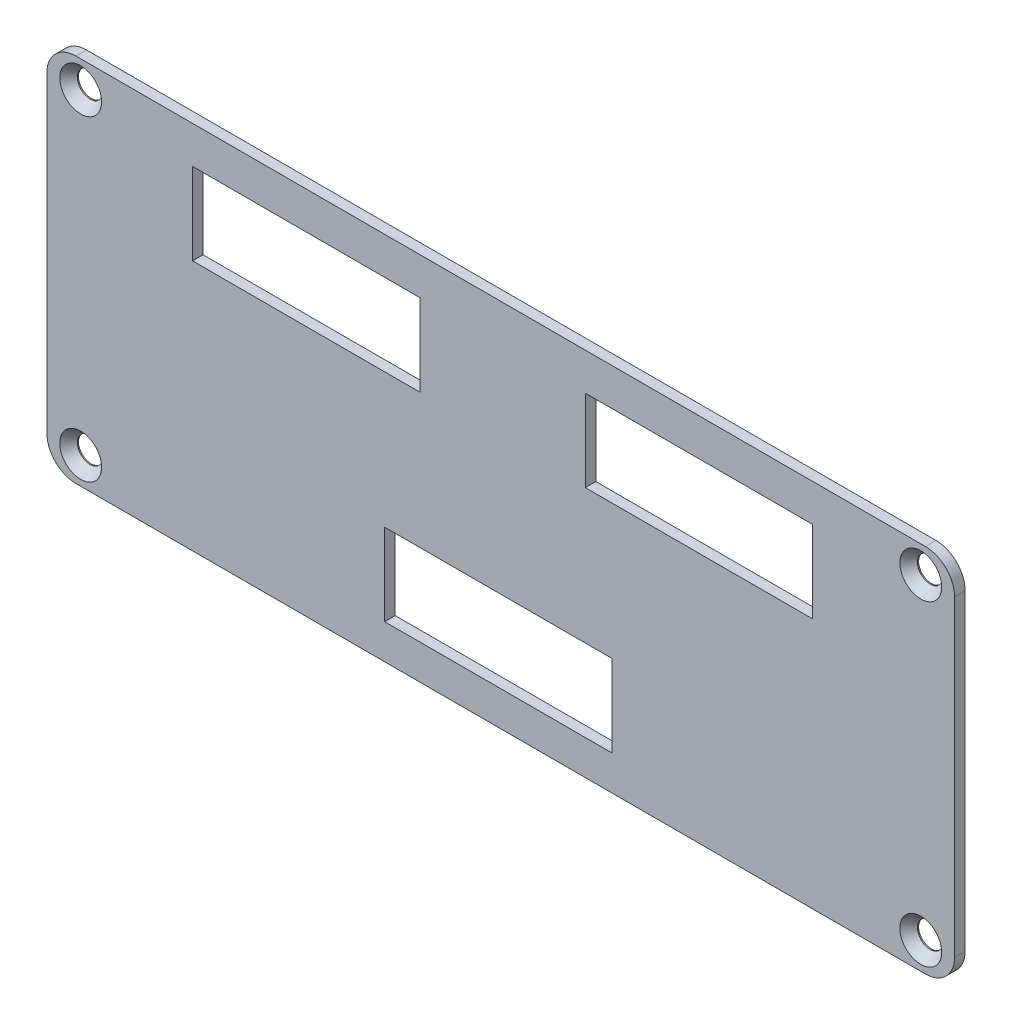
from build123d import *

# Parameters (mm, degrees)
SKETCH1_W                                      = 124.8
SKETCH1_H                                      = 50.9
BOSS_EXTRUDE1_DEPTH                            = 1.45
CSK_FOR_M3_5_FLAT_HEAD_MACHINE_SCREW1_AT_COUNT = 2
CSK_FOR_M3_5_FLAT_HEAD_MACHINE_SCREW1_AT_PITCH = 115.5
CSK_FOR_M3_5_FLAT_HEAD_MACHINE_SCREW_2_COUNT   = 2
CSK_FOR_M3_5_FLAT_HEAD_MACHINE_SCREW_2_PITCH   = 123.420014584
CSK_FOR_M3_5_FLAT_HEAD_MACHINE_SCREW_3_COUNT   = 2
CSK_FOR_M3_5_FLAT_HEAD_MACHINE_SCREW_3_PITCH   = 43.5
FILLET2_R                                      = 4
SKETCH4_W                                      = 31.25
SKETCH4_H                                      = 11.25
CUT_EXTRUDE1_DEPTH                             = 1.45


with BuildPart() as part:
    # Sketch1 → Boss-Extrude1 (new body)
    with BuildSketch(Plane.XY):
        with Locations((62.4, -25.45)):
            Rectangle(SKETCH1_W, SKETCH1_H)
    extrude(amount=BOSS_EXTRUDE1_DEPTH)

    # Sketch2 → CSK for M3.5 Flat Head Machine Screw1 (revolve, cut)
    with BuildSketch(Plane(origin=(4.65, -3.7, 1.45), x_dir=(0, -1, 0), z_dir=(1, 0, 0))):
        Polygon((0, 0), (0, 1.45), (1.75, 1.45), (1.75, 1.294164458), (2.875, 0), align=None)
    csk_for_m3_5_flat_head_machine_screw1 = revolve(axis=Axis((4.65, -3.7, 7.8), (0, 0, -1)), mode=Mode.SUBTRACT)

    # CSK for M3.5 Flat Head Machine Screw1 at: CSK for M3.5 Flat Head Machine Screw1 ×2
    with Locations(*[(i * CSK_FOR_M3_5_FLAT_HEAD_MACHINE_SCREW1_AT_PITCH, 0, 0) for i in range(1, CSK_FOR_M3_5_FLAT_HEAD_MACHINE_SCREW1_AT_COUNT)]):
        add(csk_for_m3_5_flat_head_machine_screw1, mode=Mode.SUBTRACT)

    # CSK for M3.5 Flat Head Machine Screw 2: CSK for M3.5 Flat Head Machine Screw1 ×2
    with Locations(*[Vector(0.935828766, -0.35245499, 0) * (i * CSK_FOR_M3_5_FLAT_HEAD_MACHINE_SCREW_2_PITCH) for i in range(1, CSK_FOR_M3_5_FLAT_HEAD_MACHINE_SCREW_2_COUNT)]):
        add(csk_for_m3_5_flat_head_machine_screw1, mode=Mode.SUBTRACT)

    # CSK for M3.5 Flat Head Machine Screw 3: CSK for M3.5 Flat Head Machine Screw1 ×2
    with Locations(*[(0, -i * CSK_FOR_M3_5_FLAT_HEAD_MACHINE_SCREW_3_PITCH, 0) for i in range(1, CSK_FOR_M3_5_FLAT_HEAD_MACHINE_SCREW_3_COUNT)]):
        add(csk_for_m3_5_flat_head_machine_screw1, mode=Mode.SUBTRACT)

    # Fillet2
    fillet2_edges = [part.edges().sort_by_distance(p)[0] for p in [
        (0, 0, 0.725),
        (124.8, 0, 0.725),
        (124.8, -50.9, 0.725),
        (0, -50.9, 0.725),
    ]]
    fillet(fillet2_edges, radius=FILLET2_R)

    # Sketch4 → Cut-Extrude1 (cut)
    with BuildSketch(Plane.XY):
        with Locations((35.651, -10.75)):
            Rectangle(SKETCH4_W, SKETCH4_H)
        with Locations((89.651, -10.75)):
            Rectangle(SKETCH4_W, SKETCH4_H)
        with Locations((62.069, -40.5)):
            Rectangle(SKETCH4_W, SKETCH4_H)
    extrude(amount=CUT_EXTRUDE1_DEPTH, mode=Mode.SUBTRACT)


solid = part.part
